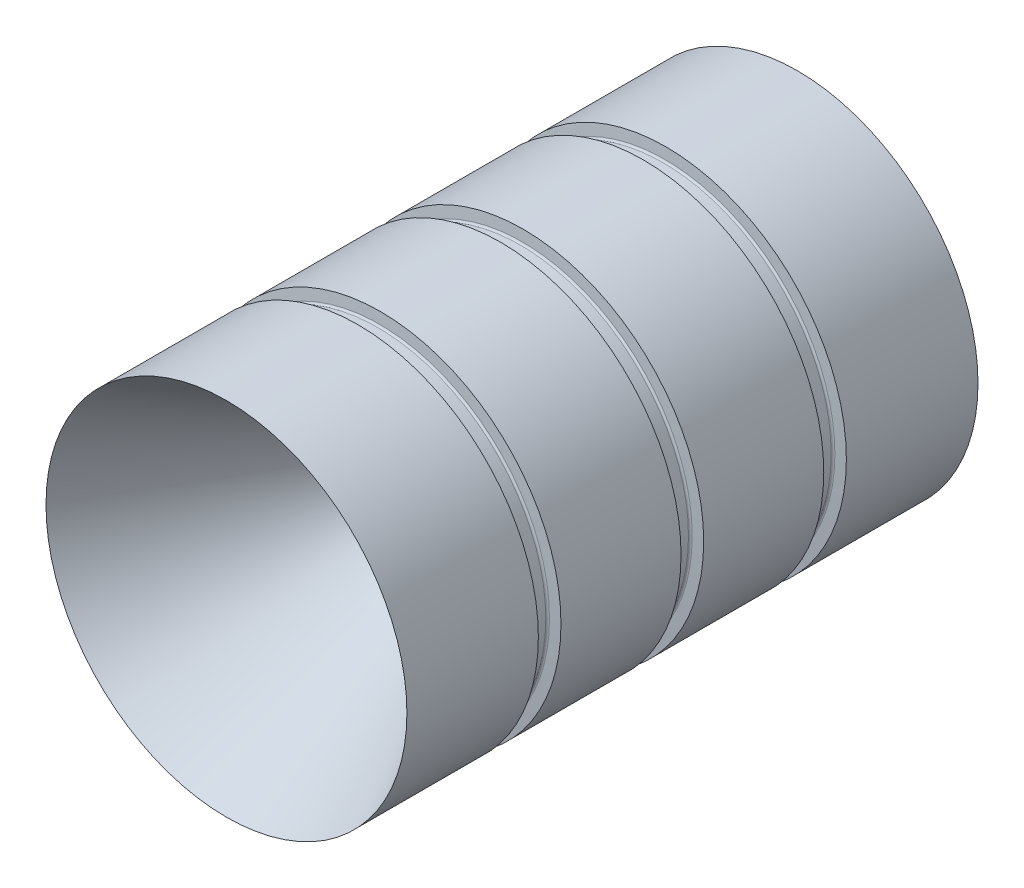
from build123d import *


with BuildPart() as part:
    # Sketch1 → Revolve1 (revolve)
    with BuildSketch(Plane(origin=(0, 0, 0), x_dir=(0, 0, -1), z_dir=(1, 0, 0))):
        with BuildLine():
            ThreePointArc((315.190684558, 15.267970122), (316.188580581, 15.353972381), (317.157047262, 15.609442831))
            add(Edge.make_bspline(
                [(317.157047262, 15.609442831), (354.250329011, 28.892986197), (394.6290315, 34.567805941)],
                knots=[0, 0, 0, 1, 1, 1], degree=2))
            Line((394.6290315, 34.567805941), (394.6290315, 41.275))
            Line((394.6290315, 41.275), (264.008615753, 41.275))
            Line((264.008615753, 41.275), (309.054125739, 15.267970122))
            Line((309.054125739, 15.267970122), (315.190684558, 15.267970122))
        make_face()
    revolve(axis=Axis((0, 0, 0), (0, 0, -1)))

    # Sketch9 → Groove for AS 568-234, O-Ring1 (revolve, cut)
    with BuildSketch(Plane(origin=(0, 0, 0), x_dir=(0, -1, 0), z_dir=(-1, 0, 0))):
        with BuildLine():
            Line((38.861359272, -294.283287556), (41.3639, -294.064343613))
            Line((41.3639, -294.064343613), (41.3639, -299.2520315))
            Line((41.3639, -299.2520315), (38.861359272, -299.033087556))
            ThreePointArc((38.861359272, -299.033087556), (38.572380224, -298.89057886), (38.4556, -298.590279013))
            Line((38.4556, -298.590279013), (38.4556, -294.7260961))
            ThreePointArc((38.4556, -294.7260961), (38.572380224, -294.425796252), (38.861359272, -294.283287556))
        make_face()
    revolve(axis=Axis((0, 0, 50), (0, 0, -1)), mode=Mode.SUBTRACT)

    # Sketch11 → Groove for AS 568-234, O-Ring2 (revolve, cut)
    with BuildSketch(Plane(origin=(0, 0, 0), x_dir=(0, -1, 0), z_dir=(-1, 0, 0))):
        with BuildLine():
            Line((38.861359272, -326.922287556), (41.3639, -326.703343613))
            Line((41.3639, -326.703343613), (41.3639, -331.8910315))
            Line((41.3639, -331.8910315), (38.861359272, -331.672087556))
            ThreePointArc((38.861359272, -331.672087556), (38.572380224, -331.52957886), (38.4556, -331.229279013))
            Line((38.4556, -331.229279013), (38.4556, -327.3650961))
            ThreePointArc((38.4556, -327.3650961), (38.572380224, -327.064796252), (38.861359272, -326.922287556))
        make_face()
    revolve(axis=Axis((0, 0, 50), (0, 0, -1)), mode=Mode.SUBTRACT)

    # Sketch13 → Groove for AS 568-234, O-Ring3 (revolve, cut)
    with BuildSketch(Plane(origin=(0, 0, 0), x_dir=(0, -1, 0), z_dir=(-1, 0, 0))):
        with BuildLine():
            Line((38.861359272, -359.561287556), (41.3639, -359.342343613))
            Line((41.3639, -359.342343613), (41.3639, -364.5300315))
            Line((41.3639, -364.5300315), (38.861359272, -364.311087556))
            ThreePointArc((38.861359272, -364.311087556), (38.572380224, -364.16857886), (38.4556, -363.868279013))
            Line((38.4556, -363.868279013), (38.4556, -360.0040961))
            ThreePointArc((38.4556, -360.0040961), (38.572380224, -359.703796252), (38.861359272, -359.561287556))
        make_face()
    revolve(axis=Axis((0, 0, 50), (0, 0, -1)), mode=Mode.SUBTRACT)


solid = part.part
